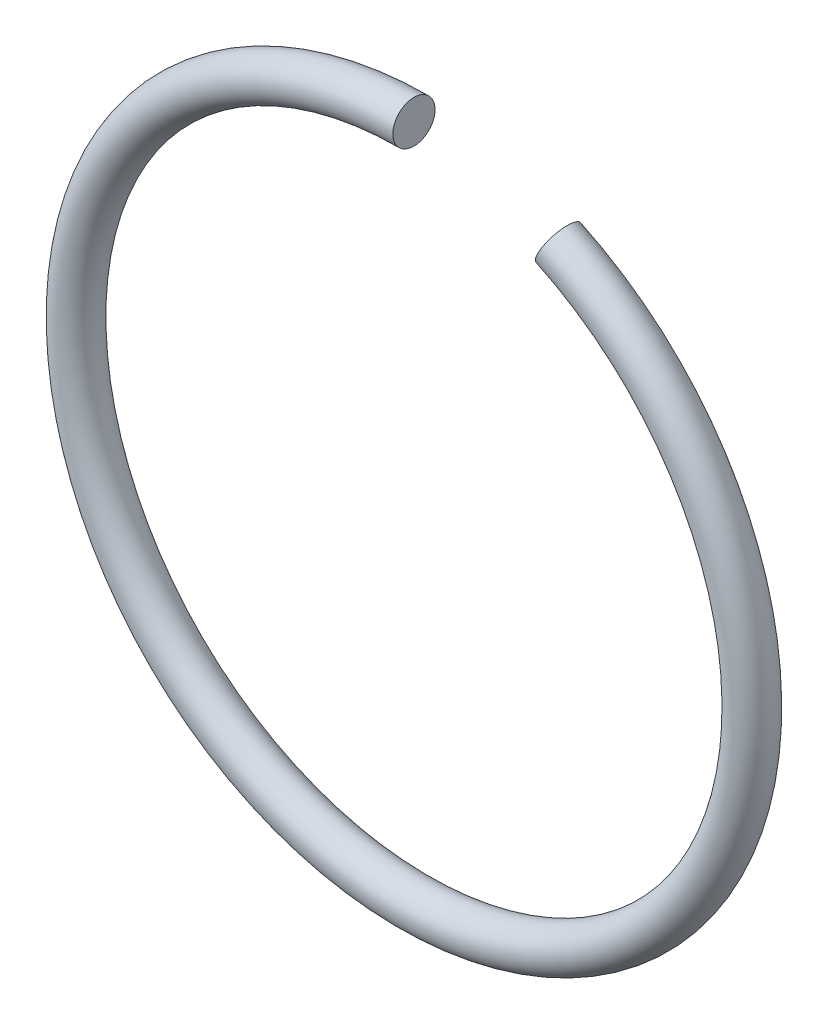
from build123d import *

# Parameters (mm, degrees)
SKETCH2_R = 0.5


with BuildPart() as part:
    # Sweep1: sweep along a path in Sketch1
    with BuildLine(Plane.XY) as sweep1_path:
        ThreePointArc((0, 8), (-1.75, -7.806247498), (3.41523328, 7.234375))
    # Sketch2 → Sweep1 (sweep)
    with BuildSketch(Plane(origin=(0, 0, 0), x_dir=(0, 0, -1), z_dir=(1, 0, 0))):
        with Locations((0, 8)):
            Circle(SKETCH2_R)
    sweep(path=sweep1_path.line)


solid = part.part
